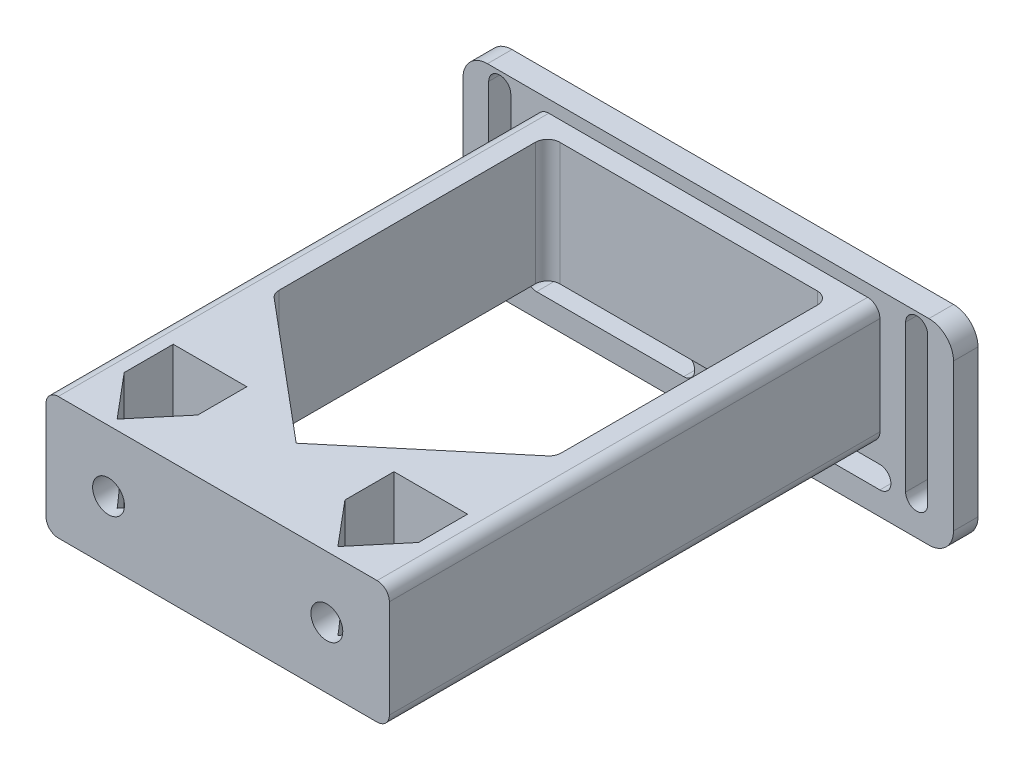
from build123d import *

# Parameters (mm, degrees)
SKETCH1_W           = 100
SKETCH1_H           = 40
BOSS_EXTRUDE1_DEPTH = 5
CUT_EXTRUDE1_DEPTH  = 5
CUT_EXTRUDE2_DEPTH  = 5
CUT_EXTRUDE3_DEPTH  = 5
CUT_EXTRUDE4_DEPTH  = 5
SKETCH3_W           = 70
SKETCH3_H           = 25
BOSS_EXTRUDE2_DEPTH = 100
FILLET1_R           = 5
FILLET2_R           = 2.5
CUT_EXTRUDE8_DEPTH  = 120.504184027
FILLET3_R           = 2.5
CUT_EXTRUDE9_DEPTH  = 120.504184027
CUT_EXTRUDE10_REACH = 120.004
SKETCH10_R          = 3.25


with BuildPart() as part:
    # Sketch1 → Boss-Extrude1 (new body)
    with BuildSketch(Plane.XY):
        Rectangle(SKETCH1_W, SKETCH1_H)
    extrude(amount=BOSS_EXTRUDE1_DEPTH)

    # Sketch2 → Cut-Extrude1 (cut)
    with BuildSketch(Plane.XY.offset(5)):
        with BuildLine():
            Line((-40.25, 17), (-40.25, -13))
            ThreePointArc((-40.25, -13), (-42.5, -15.25), (-44.75, -13))
            Line((-44.75, -13), (-44.75, 17))
            ThreePointArc((-44.75, 17), (-42.5, 19.25), (-40.25, 17))
        make_face()
    extrude(amount=-CUT_EXTRUDE1_DEPTH, mode=Mode.SUBTRACT)

    # Sketch2_3 → Cut-Extrude2 (cut)
    with BuildSketch(Plane.XY.offset(5)):
        with BuildLine():
            Line((-35, -10.75), (-5, -10.75))
            ThreePointArc((-5, -10.75), (-2.75, -13), (-5, -15.25))
            Line((-5, -15.25), (-35, -15.25))
            ThreePointArc((-35, -15.25), (-37.25, -13), (-35, -10.75))
        make_face()
    extrude(amount=-CUT_EXTRUDE2_DEPTH, mode=Mode.SUBTRACT)

    # Sketch2_4 → Cut-Extrude3 (cut)
    with BuildSketch(Plane.XY.offset(5)):
        with BuildLine():
            Line((5, -10.75), (35, -10.75))
            ThreePointArc((35, -10.75), (37.25, -13), (35, -15.25))
            Line((35, -15.25), (5, -15.25))
            ThreePointArc((5, -15.25), (2.75, -13), (5, -10.75))
        make_face()
    extrude(amount=-CUT_EXTRUDE3_DEPTH, mode=Mode.SUBTRACT)

    # Sketch2_5 → Cut-Extrude4 (cut)
    with BuildSketch(Plane.XY.offset(5)):
        with BuildLine():
            Line((44.75, 17), (44.75, -13))
            ThreePointArc((44.75, -13), (42.5, -15.25), (40.25, -13))
            Line((40.25, -13), (40.25, 17))
            ThreePointArc((40.25, 17), (42.5, 19.25), (44.75, 17))
        make_face()
    extrude(amount=-CUT_EXTRUDE4_DEPTH, mode=Mode.SUBTRACT)

    # Sketch3 → Boss-Extrude2 (add)
    with BuildSketch(Plane.XY.offset(5)):
        with Locations((0, 5)):
            Rectangle(SKETCH3_W, SKETCH3_H)
    extrude(amount=BOSS_EXTRUDE2_DEPTH)

    # Fillet1
    fillet1_edges = [part.edges().sort_by_distance(p)[0] for p in [
        (-50, 20, 2.5),
        (50, 20, 2.5),
        (50, -20, 2.5),
        (-50, -20, 2.5),
    ]]
    fillet(fillet1_edges, radius=FILLET1_R)

    # Fillet2
    fillet2_edges = [part.edges().sort_by_distance(p)[0] for p in [
        (-35, 17.5, 55),
        (35, 17.5, 55),
        (35, -7.5, 55),
        (-35, -7.5, 55),
    ]]
    fillet(fillet2_edges, radius=FILLET2_R)

    # Sketch8 → Cut-Extrude8 (cut, through all)
    with BuildSketch(Plane.XZ.offset(7.5)):
        Polygon((-28.75, 9), (28.75, 9), (28.75, 64.875885604), (0, 89), (-28.75, 64.875885604), align=None)
    extrude(amount=-CUT_EXTRUDE8_DEPTH, mode=Mode.SUBTRACT)

    # Fillet3
    fillet3_edges = [part.edges().sort_by_distance(p)[0] for p in [
        (28.75, 5, 64.875885604),
        (-28.75, 5, 64.875885604),
        (28.75, 5, 9),
        (-28.75, 5, 9),
    ]]
    fillet(fillet3_edges, radius=FILLET3_R)

    # Sketch9 → Cut-Extrude9 (cut, through all)
    with BuildSketch(Plane.XZ.offset(7.5)):
        Polygon((-30, 94.061848056), (-30, 84.061848056), (-15, 84.061848056), (-15, 94.061848056), (-22.5, 103), align=None)
        Polygon((15, 94.061848056), (22.5, 103), (30, 94.061848056), (30, 84.061848056), (15, 84.061848056), align=None)
    extrude(amount=-CUT_EXTRUDE9_DEPTH, mode=Mode.SUBTRACT)

    # Sketch10 → Cut-Extrude10 (cut, up to next)
    with BuildSketch(Plane.XY.offset(105), mode=Mode.PRIVATE) as cut_extrude10_sk1:
        with Locations((-22.252451, 5)):
            Circle(SKETCH10_R)
    cut_extrude10_tool1 = extrude(cut_extrude10_sk1.sketch, amount=-CUT_EXTRUDE10_REACH, mode=Mode.PRIVATE) & part.part
    # Sketch10 → Cut-Extrude10 (cut, up to next)
    with BuildSketch(Plane.XY.offset(105), mode=Mode.PRIVATE) as cut_extrude10_sk2:
        with Locations((22.252451, 5)):
            Circle(SKETCH10_R)
    cut_extrude10_tool2 = extrude(cut_extrude10_sk2.sketch, amount=-CUT_EXTRUDE10_REACH, mode=Mode.PRIVATE) & part.part
    add(cut_extrude10_tool1.solids().sort_by_distance((-22.252451, 5, 105))[0], mode=Mode.SUBTRACT)
    add(cut_extrude10_tool2.solids().sort_by_distance((22.252451, 5, 105))[0], mode=Mode.SUBTRACT)


solid = part.part
